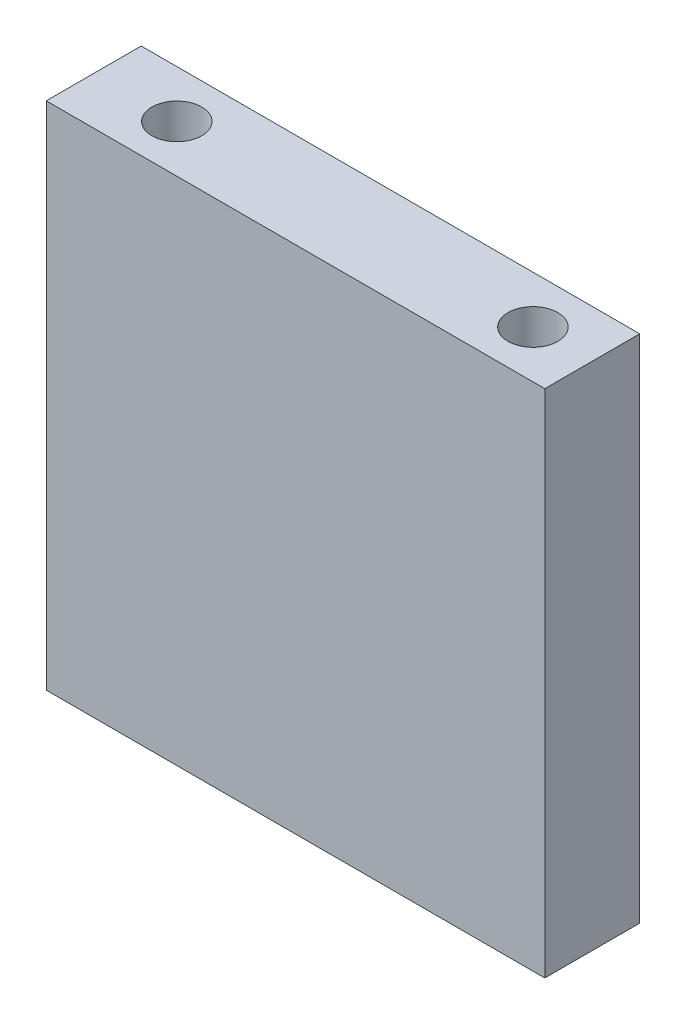
from build123d import *

# Parameters (mm, degrees)
SKETCH1_W           = 42
SKETCH1_H           = 43
BOSS_EXTRUDE1_DEPTH = 8
SKETCH2_R           = 2.1
CUT_EXTRUDE1_DEPTH  = 10
SKETCH3_R           = 2.1
CUT_EXTRUDE2_DEPTH  = 10


with BuildPart() as part:
    # Sketch1 → Boss-Extrude1 (new body)
    with BuildSketch(Plane.XY):
        with Locations((21, 21.5)):
            Rectangle(SKETCH1_W, SKETCH1_H)
    extrude(amount=BOSS_EXTRUDE1_DEPTH)

    # Sketch2 → Cut-Extrude1 (cut)
    with BuildSketch(Plane.XZ):
        with Locations((37, 4)):
            Circle(SKETCH2_R)
        with Locations((7, 4)):
            Circle(SKETCH2_R)
    extrude(amount=-CUT_EXTRUDE1_DEPTH, mode=Mode.SUBTRACT)

    # Sketch3 → Cut-Extrude2 (cut)
    with BuildSketch(Plane(origin=(0, 43, 0), x_dir=(1, 0, 0), z_dir=(0, 1, 0))):
        with Locations((37, -4)):
            Circle(SKETCH3_R)
        with Locations((7, -4)):
            Circle(SKETCH3_R)
    extrude(amount=-CUT_EXTRUDE2_DEPTH, mode=Mode.SUBTRACT)


solid = part.part
